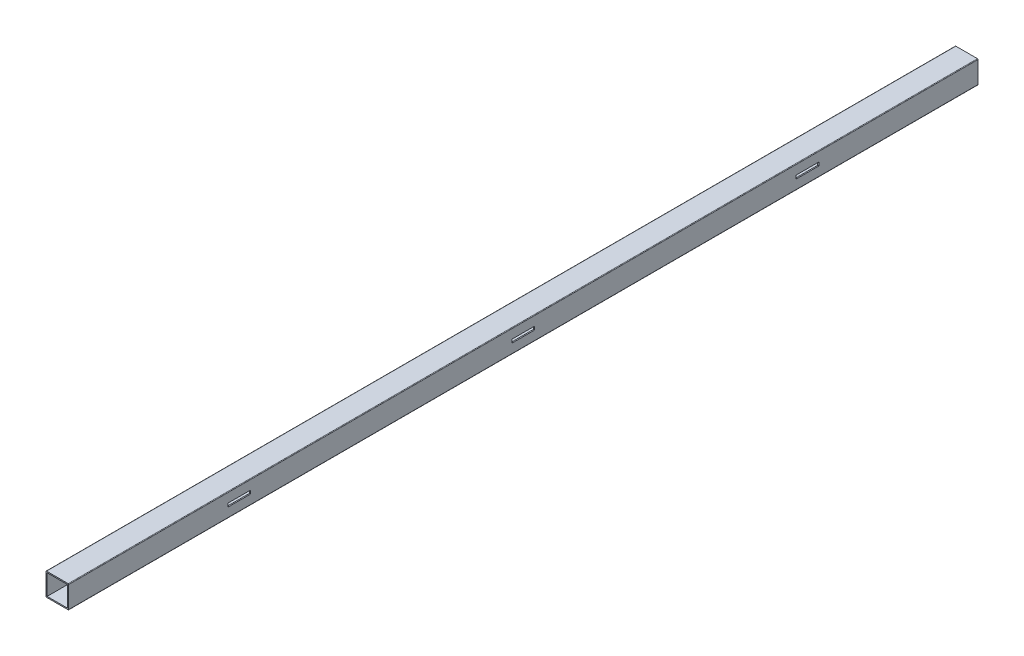
from build123d import *

# Parameters (mm, degrees)
SKETCH1_W           = 18
SKETCH1_H           = 18
EXTRUDE_THIN1_DEPTH = 800
SKETCH2_W           = 20
SKETCH2_H           = 3
CUT_EXTRUDE1_DEPTH  = 10
SKETCH3_R           = 2.5
CUT_EXTRUDE2_DEPTH  = 10


with BuildPart() as part:
    # Sketch1 → Extrude-Thin1 (new body)
    with BuildSketch(Plane.XY):
        with BuildLine():
            Line((-10, 9.5), (-10, -9.5))
            ThreePointArc((-10, -9.5), (-9.853553391, -9.853553391), (-9.5, -10))
            Line((-9.5, -10), (9.5, -10))
            ThreePointArc((9.5, -10), (9.853553391, -9.853553391), (10, -9.5))
            Line((10, -9.5), (10, 9.5))
            ThreePointArc((10, 9.5), (9.853553391, 9.853553391), (9.5, 10))
            Line((9.5, 10), (-9.5, 10))
            ThreePointArc((-9.5, 10), (-9.853553391, 9.853553391), (-10, 9.5))
        make_face()
        Rectangle(SKETCH1_W, SKETCH1_H, mode=Mode.SUBTRACT)
    extrude(amount=EXTRUDE_THIN1_DEPTH)

    # Sketch2 → Cut-Extrude1 (cut)
    with BuildSketch(Plane(origin=(10, 0, 0), x_dir=(0, 0, -1), z_dir=(1, 0, 0))):
        with Locations((-150, 0)):
            Rectangle(SKETCH2_W, SKETCH2_H)
        with Locations((-400, 0)):
            Rectangle(SKETCH2_W, SKETCH2_H)
        with Locations((-650, 0)):
            Rectangle(SKETCH2_W, SKETCH2_H)
    extrude(amount=-CUT_EXTRUDE1_DEPTH, mode=Mode.SUBTRACT)

    # Sketch3 → Cut-Extrude2 (cut)
    with BuildSketch(Plane.XZ.offset(10)):
        with Locations((0, 25)):
            Circle(SKETCH3_R)
        with Locations((0, 275)):
            Circle(SKETCH3_R)
        with Locations((0, 525)):
            Circle(SKETCH3_R)
        with Locations((0, 775)):
            Circle(SKETCH3_R)
    extrude(amount=-CUT_EXTRUDE2_DEPTH, mode=Mode.SUBTRACT)


solid = part.part
